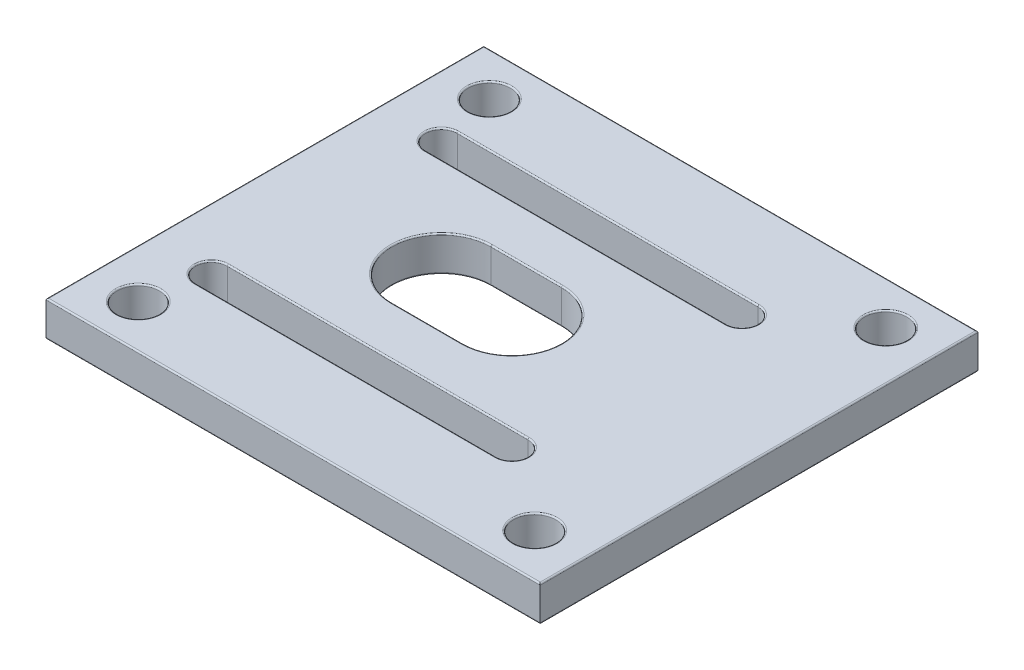
from build123d import *

# Parameters (mm, degrees)
SKETCH1_W           = 70
SKETCH1_H           = 62
SKETCH1_R           = 3
BOSS_EXTRUDE2_DEPTH = 5
FILLET1_R           = 0.2


with BuildPart() as part:
    # Sketch1 → Boss-Extrude2 (new body)
    with BuildSketch(Plane(origin=(0, 0, 0), x_dir=(1, 0, 0), z_dir=(0, 1, 0))):
        Rectangle(SKETCH1_W, SKETCH1_H)
        with Locations((-28.072056756, 24.863821699)):
            Circle(SKETCH1_R, mode=Mode.SUBTRACT)
        with Locations((28.072056756, 24.863821699)):
            Circle(SKETCH1_R, mode=Mode.SUBTRACT)
        with Locations((28.072056756, -24.863821699)):
            Circle(SKETCH1_R, mode=Mode.SUBTRACT)
        with Locations((-28.072056756, -24.863821699)):
            Circle(SKETCH1_R, mode=Mode.SUBTRACT)
        with BuildLine():
            Line((-26.287956399, 18.537956399), (16.287956399, 18.537956399))
            ThreePointArc((16.287956399, 18.537956399), (18.537956399, 16.287956399), (16.287956399, 14.037956399))
            Line((16.287956399, 14.037956399), (-26.287956399, 14.037956399))
            ThreePointArc((-26.287956399, 14.037956399), (-28.537956399, 16.287956399), (-26.287956399, 18.537956399))
        make_face(mode=Mode.SUBTRACT)
        with BuildLine():
            Line((-10, 7), (0, 7))
            ThreePointArc((0, 7), (7, 0), (0, -7))
            Line((0, -7), (-10, -7))
            ThreePointArc((-10, -7), (-17, 0), (-10, 7))
        make_face(mode=Mode.SUBTRACT)
        with BuildLine():
            Line((-26.287956399, -18.537956399), (16.287956399, -18.537956399))
            ThreePointArc((16.287956399, -18.537956399), (18.537956399, -16.287956399), (16.287956399, -14.037956399))
            Line((16.287956399, -14.037956399), (-26.287956399, -14.037956399))
            ThreePointArc((-26.287956399, -14.037956399), (-28.537956399, -16.287956399), (-26.287956399, -18.537956399))
        make_face(mode=Mode.SUBTRACT)
    extrude(amount=BOSS_EXTRUDE2_DEPTH)

    # Fillet1
    fillet1_edges = [part.edges().sort_by_distance(p)[0] for p in [
        (-31.072056756, 0, -24.863821699),
        (-31.072056756, 5, -24.863821699),
        (-35, 5, 0),
        (25.072056756, 0, -24.863821699),
        (25.072056756, 5, -24.863821699),
        (0, 5, 31),
        (25.072056756, 0, 24.863821699),
        (25.072056756, 5, 24.863821699),
        (-31.072056756, 0, 24.863821699),
        (-31.072056756, 5, 24.863821699),
        (-28.537956399, 0, -16.287956399),
        (-5, 0, -14.037956399),
        (18.537956399, 0, -16.287956399),
        (-5, 0, -18.537956399),
        (-28.537956399, 5, -16.287956399),
        (-5, 5, -14.037956399),
        (18.537956399, 5, -16.287956399),
        (-5, 5, -18.537956399),
        (-17, 0, 0),
        (-5, 0, 7),
        (7, 0, 0),
        (-5, 0, -7),
        (-17, 5, 0),
        (-5, 5, 7),
        (7, 5, 0),
        (-5, 5, -7),
        (35, 5, 0),
        (0, 0, 31),
        (-35, 0, 0),
        (-28.537956399, 0, 16.287956399),
        (-5, 0, 18.537956399),
        (18.537956399, 0, 16.287956399),
        (-5, 0, 14.037956399),
        (0, 0, -31),
        (-28.537956399, 5, 16.287956399),
        (-5, 5, 18.537956399),
        (18.537956399, 5, 16.287956399),
        (-5, 5, 14.037956399),
        (35, 0, 0),
        (0, 5, -31),
    ]]
    fillet(fillet1_edges, radius=FILLET1_R)


solid = part.part
